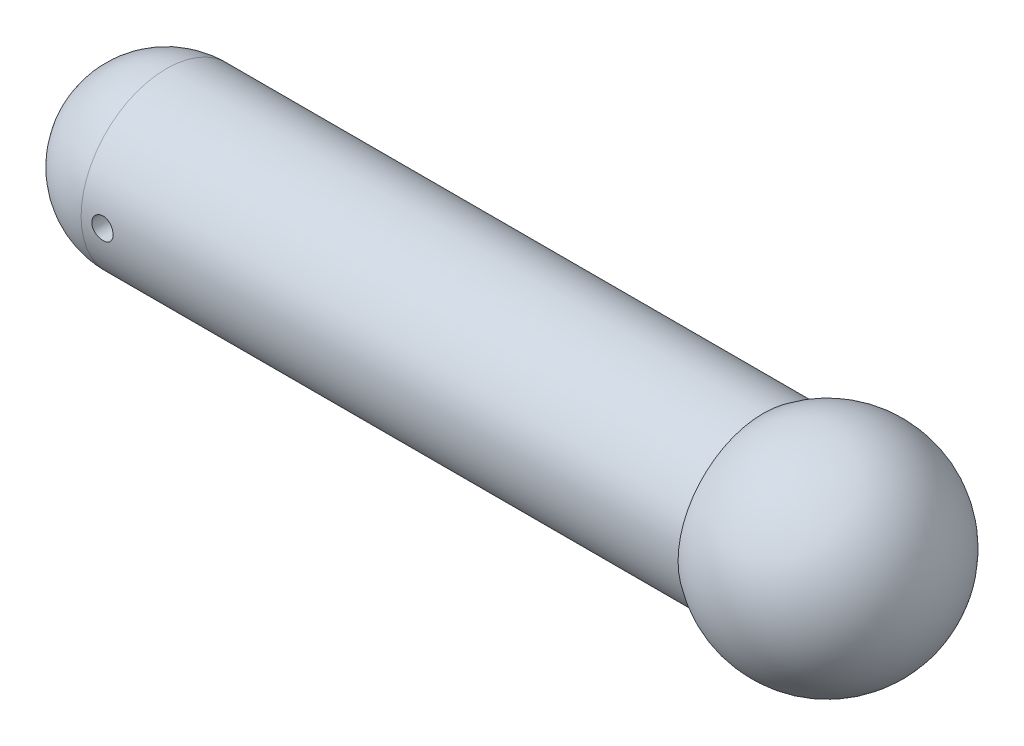
from build123d import *

# Parameters (mm, degrees)
CROQUIS6_R                 = 2.5
CORTAR_EXTRUIR1_DEPTH      = 26
CORTAR_EXTRUIR1_DEPTH_BACK = 26


with BuildPart() as part:
    # Croquis3 → Revolución10 (revolve)
    with BuildSketch(Plane(origin=(0, 0, 0), x_dir=(1, 0, 0), z_dir=(0, 1, 0))):
        with BuildLine():
            Line((-32.919254658, 20), (107.080745342, 20))
            ThreePointArc((107.080745342, 20), (133.261085229, 22.360679775), (147.080745342, 0))
            Line((147.080745342, 0), (-52.919254658, 0))
            ThreePointArc((-52.919254658, 0), (-47.061390282, 14.142135624), (-32.919254658, 20))
        make_face()
    revolve(axis=Axis((-63.085280919, 0, 0), (1, 0, 0)))

    # Croquis6 → Cortar-Extruir1 (cut, two sides)
    with BuildSketch(Plane.XY) as cortar_extruir1_sk:
        with Locations((-27.919254658, 0)):
            Circle(CROQUIS6_R)
    extrude(amount=CORTAR_EXTRUIR1_DEPTH, mode=Mode.SUBTRACT)
    extrude(cortar_extruir1_sk.sketch, amount=-CORTAR_EXTRUIR1_DEPTH_BACK, mode=Mode.SUBTRACT)


solid = part.part
